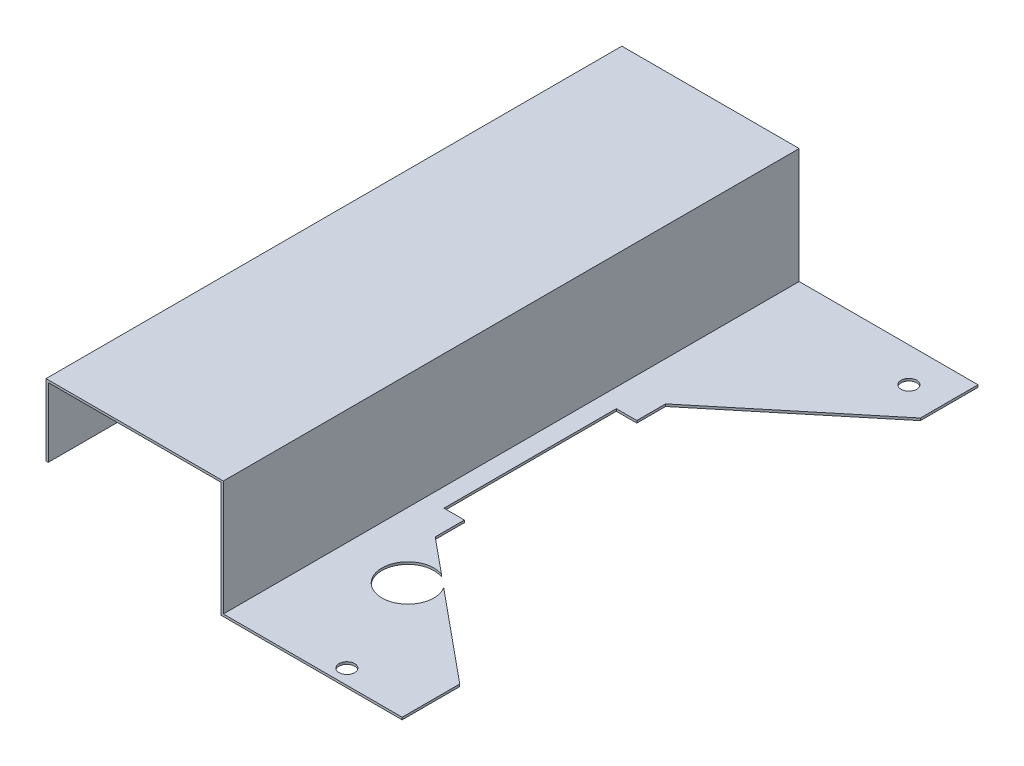
from build123d import *

# Parameters (mm, degrees)
BOSS_EXTRUDE1_DEPTH     = 125
BOSS_EXTRUDE3_DEPTH     = 1
TAP_DRILL_FOR_M8_TAP1_D = 6.8
SKETCH7_R               = 11.28805381
CUT_EXTRUDE1_DEPTH      = 1
SKETCH8_W               = 17.605373939
SKETCH8_H               = 74.840918302
CUT_EXTRUDE2_DEPTH      = 1


with BuildPart() as part:
    # Sketch1 → Boss-Extrude1 (new body, symmetric)
    with BuildSketch(Plane.XY):
        Polygon((-13.181947142, 17.7), (-13.181947142, 47.7), (61.818052858, 47.7), (61.818052858, -2.3), (79.818052858, -2.3), (79.818052858, -1.3), (62.818052858, -1.3), (62.818052858, 48.7), (-14.181947142, 48.7), (-14.181947142, 17.7), align=None)
    extrude(amount=BOSS_EXTRUDE1_DEPTH, both=True)

    # Sketch2 → Boss-Extrude3 (add)
    with BuildSketch(Plane.XZ.offset(2.3)):
        Polygon((79.818052858, 125), (79.818052858, 50), (140.446405645, 100), (140.446405645, 125), align=None)
        Polygon((79.818052858, -50), (79.818052858, -125), (140.446405645, -125), (140.446405645, -100), align=None)
    extrude(amount=-BOSS_EXTRUDE3_DEPTH)

    # Tap Drill for M8 Tap1 (through all)
    with Locations(Plane(origin=(0, -2.3, 0), x_dir=(-1, 0, 0), z_dir=(0, -1, 0))):
        with Locations((-125.446405645, 110), (-109.974750597, -118.548748507)):
            Hole(TAP_DRILL_FOR_M8_TAP1_D / 2)

    # Sketch7 → Cut-Extrude1 (cut)
    with BuildSketch(Plane.XZ.offset(2.3)):
        with Locations((91.223262411, 73.278651414)):
            Circle(SKETCH7_R)
    extrude(amount=-CUT_EXTRUDE1_DEPTH, mode=Mode.SUBTRACT)

    # Sketch8 → Cut-Extrude2 (cut)
    with BuildSketch(Plane.XZ.offset(2.3)):
        with Locations((79.721629834, -0.077471799)):
            Rectangle(SKETCH8_W, SKETCH8_H)
    extrude(amount=-CUT_EXTRUDE2_DEPTH, mode=Mode.SUBTRACT)


solid = part.part
